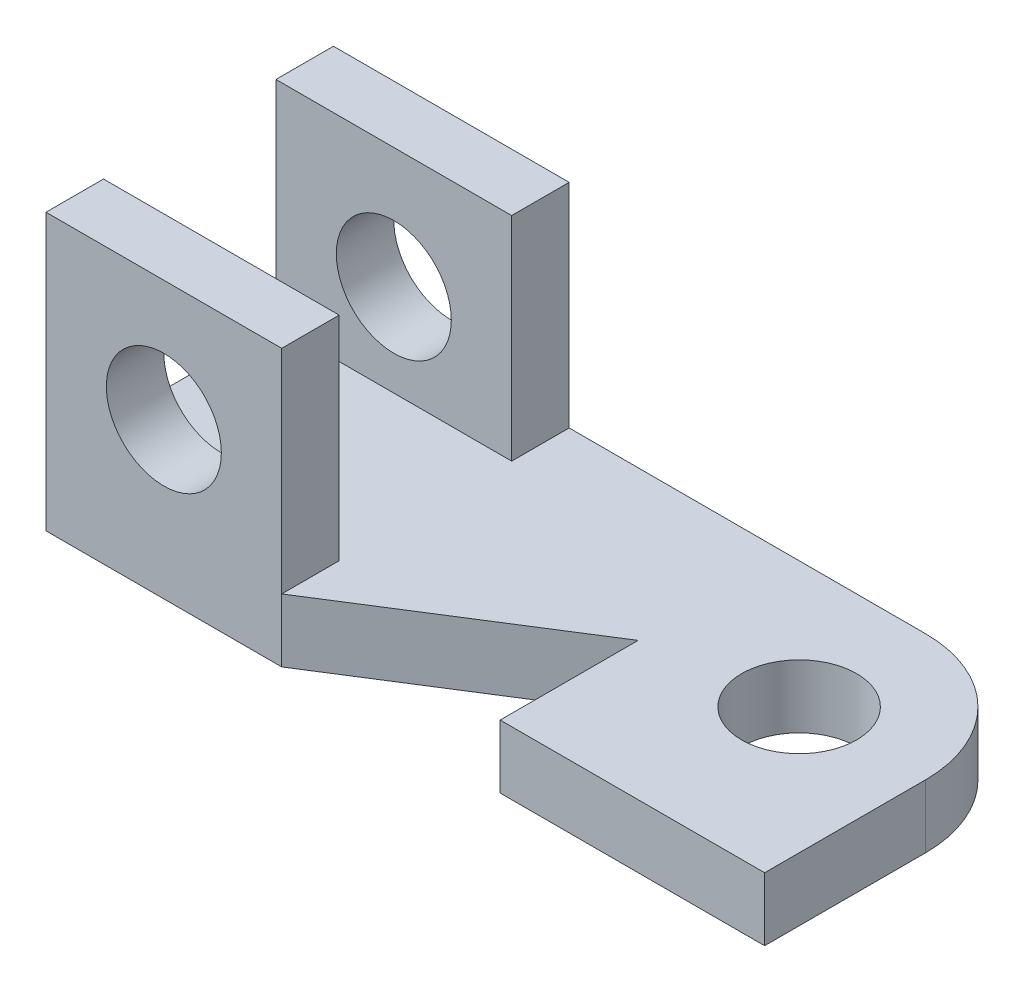
from build123d import *

# Parameters (mm, degrees)
SKETCH1_R           = 100
BOSS_EXTRUDE1_DEPTH = 110
SKETCH2_W           = 410
SKETCH2_H           = 100
BOSS_EXTRUDE2_DEPTH = 370
SKETCH3_R           = 100
CUT_EXTRUDE1_DEPTH  = 501


with BuildPart() as part:
    # Sketch1 → Boss-Extrude1 (new body)
    with BuildSketch(Plane(origin=(0, 0, 0), x_dir=(1, 0, 0), z_dir=(0, 1, 0))):
        with BuildLine():
            Line((-460, 0), (-460, 240))
            Line((-460, 240), (-840, 0))
            Line((-840, 0), (-1250, 0))
            Line((-1250, 0), (-1250, 500))
            Line((-1250, 500), (-220, 500))
            ThreePointArc((-220, 500), (-64.436508139, 435.563491861), (0, 280))
            Line((0, 280), (0, 0))
            Line((0, 0), (-460, 0))
        make_face()
        with Locations((-220, 280)):
            Circle(SKETCH1_R, mode=Mode.SUBTRACT)
    extrude(amount=BOSS_EXTRUDE1_DEPTH)

    # Sketch2 → Boss-Extrude2 (add)
    with BuildSketch(Plane(origin=(0, 110, 0), x_dir=(1, 0, 0), z_dir=(0, 1, 0))):
        with Locations((-1045, 450)):
            Rectangle(SKETCH2_W, SKETCH2_H)
        with Locations((-1045, 50)):
            Rectangle(SKETCH2_W, SKETCH2_H)
    extrude(amount=BOSS_EXTRUDE2_DEPTH)

    # Sketch3 → Cut-Extrude1 (cut, through all)
    with BuildSketch(Plane.XY):
        with Locations((-1045, 270)):
            Circle(SKETCH3_R)
    extrude(amount=-CUT_EXTRUDE1_DEPTH, mode=Mode.SUBTRACT)


solid = part.part
